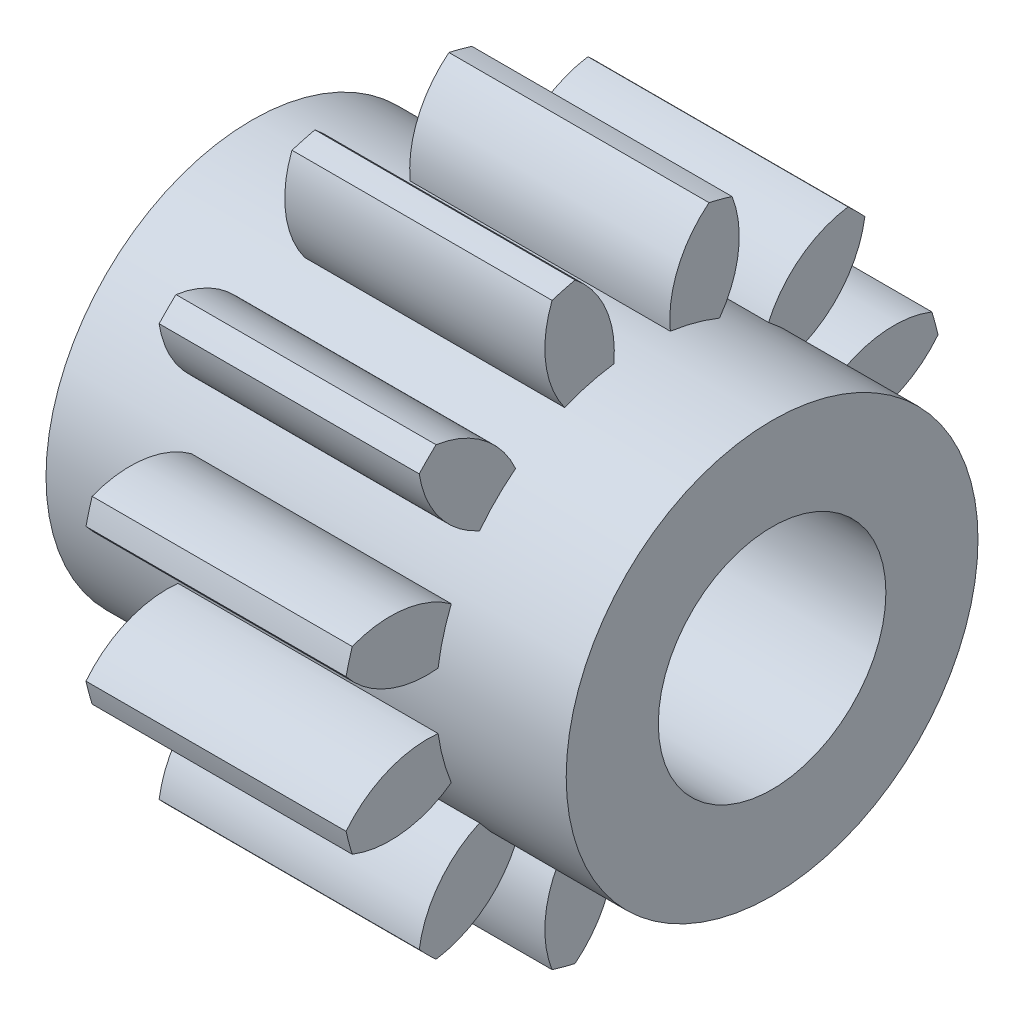
from build123d import *
from build123d.topology import SkipClean

# Parameters (mm, degrees)
BASPROSKE_W       = 25.4
BASPROSKE_H       = 29.633333333
TOOTHCUT_DEPTH    = 50.004376222
TEETHCUTS_COUNT   = 12
TEETHCUTS_ANGLE   = 330
HUBNEABOTSKE_R    = 20.107063333
HUBNEARBOTH_DEPTH = 12.7000254
HUBFARSKE_R       = 20.107063333
HUBFAR_DEPTH      = 12.7000254
BORSKE_R          = 11.1125
BORE_DEPTH        = 50.8000508
SCALE1_SCALE      = 0.39


with BuildPart() as part:
    # BasProSke → Base-Revolve (revolve)
    with BuildSketch(Plane(origin=(0, 0, 0), x_dir=(1, 0, 0), z_dir=(0, 1, 0)), mode=Mode.PRIVATE) as base_revolve_sk:
        with Locations((12.7, 14.816666667)):
            Rectangle(BASPROSKE_W, BASPROSKE_H)
    revolve(base_revolve_sk.sketch.rotate(Axis((-10, 0, 0), (1, 0, 0)), 180), axis=Axis((-10, 0, 0), (1, 0, 0)))

    # TooCutSke → ToothCut (cut, through all)
    with BuildSketch(Plane(origin=(0, 0, 0), x_dir=(0, 0, -1), z_dir=(1, 0, 0))):
        with BuildLine():
            ThreePointArc((2.76285054, 19.91634135), (0, 20.107063333), (-2.76285054, 19.91634135))
            ThreePointArc((-2.76285054, 19.91634135), (-3.510108668, 24.907095847), (-6.566398379, 28.922705186))
            ThreePointArc((-6.566398379, 28.922705186), (0, 29.658733333), (6.566398379, 28.922705186))
            ThreePointArc((6.566398379, 28.922705186), (3.510108668, 24.907095847), (2.76285054, 19.91634135))
        make_face()
    toothcut = extrude(amount=TOOTHCUT_DEPTH, mode=Mode.SUBTRACT)

    # TeethCuts: ToothCut ×12 about axis
    teethcuts_axis = Axis((-10, 0, 0), (1, 0, 0))
    for i in range(1, TEETHCUTS_COUNT):
        add(toothcut.rotate(teethcuts_axis, i * TEETHCUTS_ANGLE / (TEETHCUTS_COUNT - 1)), mode=Mode.SUBTRACT)

    # HubNeaBotSke → HubNearBoth (add)
    with SkipClean():  # the faces are left unmerged after this step: merging them gives an invalid solid
        with BuildSketch(Plane.ZY):
            Circle(HUBNEABOTSKE_R)
        extrude(amount=HUBNEARBOTH_DEPTH)

    # HubFarSke → HubFar (add)
    with SkipClean():  # the faces are left unmerged after this step: merging them gives an invalid solid
        with BuildSketch(Plane(origin=(25.4, 0, 0), x_dir=(0, 0, -1), z_dir=(1, 0, 0))):
            with Locations(Location((0, 0, 0), (0, 0, 180))):
                Circle(HUBFARSKE_R)
        extrude(amount=HUBFAR_DEPTH)

    # BorSke → Bore (cut, symmetric)
    with SkipClean():  # the faces are left unmerged after this step: merging them gives an invalid solid
        with BuildSketch(Plane(origin=(0, 0, 0), x_dir=(0, 0, -1), z_dir=(1, 0, 0))):
            with Locations(Location((0, 0, 0), (0, 0, 180))):
                Circle(BORSKE_R)
        extrude(amount=BORE_DEPTH, both=True, mode=Mode.SUBTRACT)


with BuildPart() as part_1:
    # Scale1: scaled about (12.7, 0, 0)
    add(part.part.scale(SCALE1_SCALE).moved(Location((7.747, 0, 0))))


solid = part_1.part
